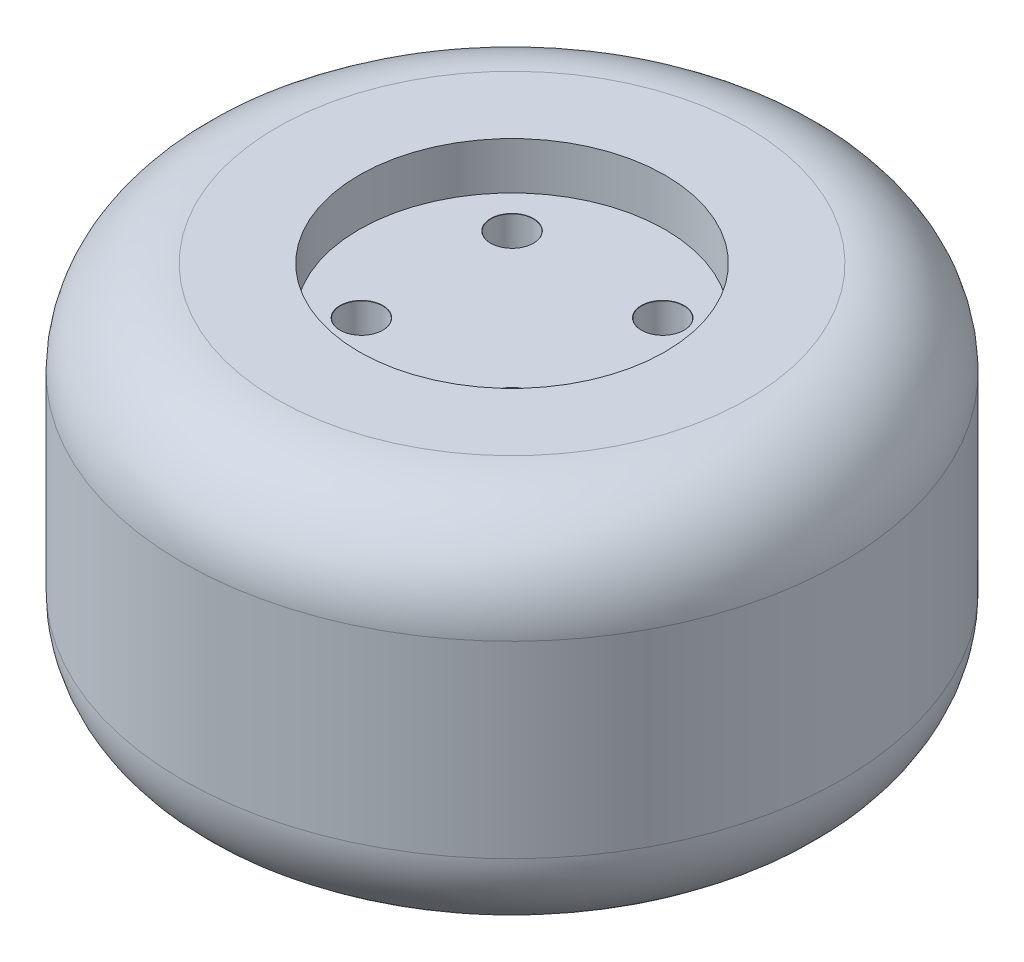
from build123d import *

# Parameters (mm, degrees)
SKETCH1_R                      = 35
BOSS_EXTRUDE1_DEPTH            = 40
SKETCH2_R                      = 16.25
CUT_EXTRUDE1_DEPTH             = 5
M4_CLEARANCE_HOLE1_D           = 4.5
M4_CLEARANCE_HOLE1_DEPTH       = 13
M4_CLEARANCE_HOLE1_CSINK_D     = 4.55
M4_CLEARANCE_HOLE1_CSINK_ANGLE = 90
M4_CLEARANCE_HOLE1_TIP         = 1.351936393
FILLET4_R                      = 10


with BuildPart() as part:
    # Sketch1 → Boss-Extrude1 (new body)
    with BuildSketch(Plane(origin=(0, 0, 0), x_dir=(1, 0, 0), z_dir=(0, 1, 0))):
        Circle(SKETCH1_R)
    extrude(amount=BOSS_EXTRUDE1_DEPTH)

    # Sketch2 → Cut-Extrude1 (cut)
    with BuildSketch(Plane(origin=(0, 40, 0), x_dir=(1, 0, 0), z_dir=(0, 1, 0))):
        Circle(SKETCH2_R)
    extrude(amount=-CUT_EXTRUDE1_DEPTH, mode=Mode.SUBTRACT)

    # M4 Clearance Hole1
    with Locations(Plane(origin=(0, 35, 0), x_dir=(1, 0, 0), z_dir=(0, 1, 0))):
        with Locations((-8, 8), (8, 8), (8, -8), (-8, -8)):
            CounterSinkHole(M4_CLEARANCE_HOLE1_D / 2, M4_CLEARANCE_HOLE1_CSINK_D / 2, depth=M4_CLEARANCE_HOLE1_DEPTH, counter_sink_angle=M4_CLEARANCE_HOLE1_CSINK_ANGLE)
            with Locations((0, 0, -(M4_CLEARANCE_HOLE1_DEPTH + M4_CLEARANCE_HOLE1_TIP / 2))):  # 118° drill point
                Cone(0, M4_CLEARANCE_HOLE1_D / 2, M4_CLEARANCE_HOLE1_TIP, mode=Mode.SUBTRACT)

    # Fillet4
    fillet4_edges = [part.edges().sort_by_distance(p)[0] for p in [
        (-35, 0, 0),
        (-35, 40, 0),
    ]]
    fillet(fillet4_edges, radius=FILLET4_R)


solid = part.part
